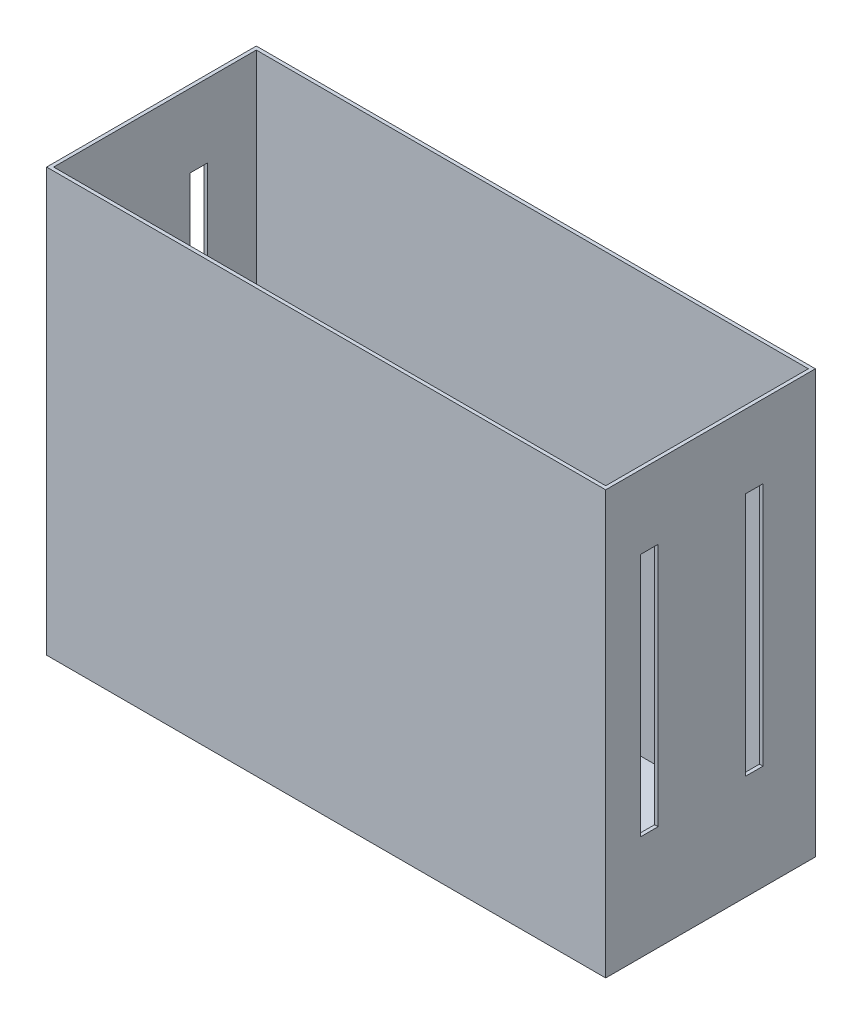
from build123d import *

# Parameters (mm, degrees)
SKETCH1_W               = 406.4
SKETCH1_H               = 152.4
SKETCH1_W_2             = 401.32
SKETCH1_H_2             = 147.32
BOSS_EXTRUDE1_DEPTH     = 304.8
SKETCH2_W               = 406.4
SKETCH2_H               = 152.4
BOSS_EXTRUDE2_DEPTH     = 2.54
SKETCH3_W               = 12.7
SKETCH3_H               = 177.8
CUT_EXTRUDE1_DEPTH      = 1
CUT_EXTRUDE1_DEPTH_BACK = 407.4


with BuildPart() as part:
    # Sketch1 → Boss-Extrude1 (new body)
    with BuildSketch(Plane(origin=(0, 0, 0), x_dir=(1, 0, 0), z_dir=(0, 1, 0))):
        Rectangle(SKETCH1_W, SKETCH1_H)
        Rectangle(SKETCH1_W_2, SKETCH1_H_2, mode=Mode.SUBTRACT)
    extrude(amount=BOSS_EXTRUDE1_DEPTH)

    # Sketch2 → Boss-Extrude2 (add)
    with BuildSketch(Plane.XZ):
        Rectangle(SKETCH2_W, SKETCH2_H)
    extrude(amount=BOSS_EXTRUDE2_DEPTH)

    # Sketch3 → Cut-Extrude1 (cut, two sides)
    with BuildSketch(Plane.ZY.offset(203.2)) as cut_extrude1_sk:
        with Locations((44.45, 162.56)):
            Rectangle(SKETCH3_W, SKETCH3_H)
        with Locations((-31.75, 162.56)):
            Rectangle(SKETCH3_W, SKETCH3_H)
    extrude(amount=CUT_EXTRUDE1_DEPTH, mode=Mode.SUBTRACT)
    extrude(cut_extrude1_sk.sketch, amount=-CUT_EXTRUDE1_DEPTH_BACK, mode=Mode.SUBTRACT)


solid = part.part
